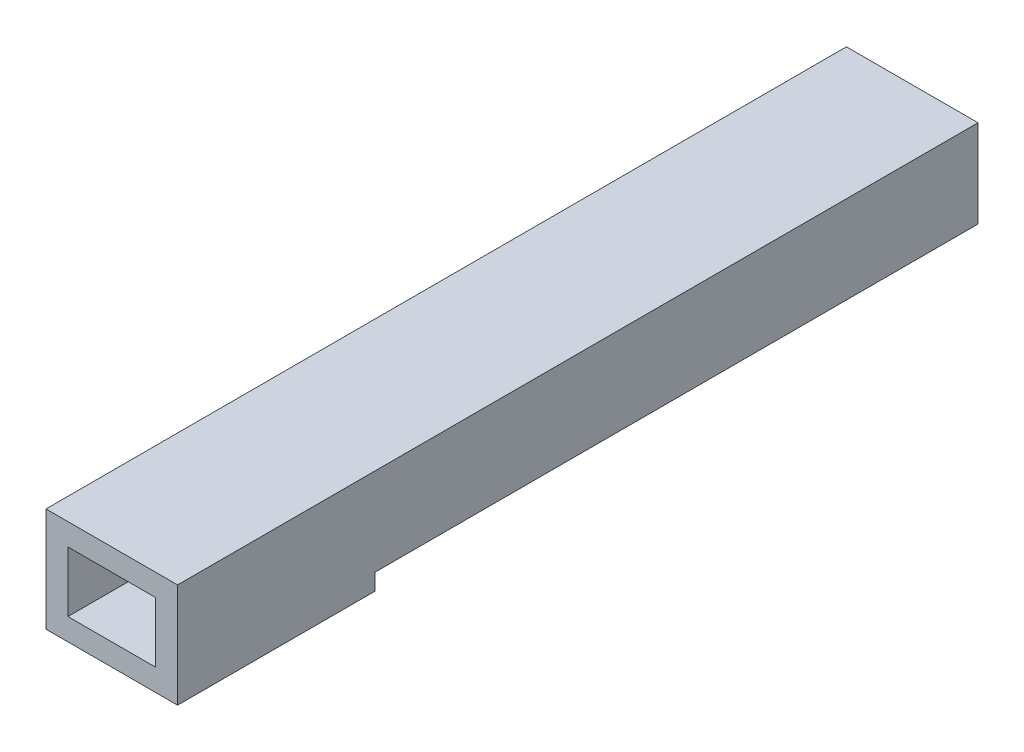
from build123d import *

# Parameters (mm, degrees)
SKETCH1_W                = 120
SKETCH1_H                = 95
SKETCH1_W_2              = 80
SKETCH1_H_2              = 55
BOSS_EXTRUDE1_DEPTH      = 156
BOSS_EXTRUDE1_DEPTH_BACK = 574
CUT_EXTRUDE1_DEPTH       = 550
CUT_EXTRUDE2_DEPTH       = 20


with BuildPart() as part:
    # Sketch1 → Boss-Extrude1 (new body, two sides)
    with BuildSketch(Plane.XY) as boss_extrude1_sk:
        with Locations((0, 212.5)):
            Rectangle(SKETCH1_W, SKETCH1_H)
        with Locations((0, 212.5)):
            Rectangle(SKETCH1_W_2, SKETCH1_H_2, mode=Mode.SUBTRACT)
    extrude(amount=BOSS_EXTRUDE1_DEPTH)
    extrude(boss_extrude1_sk.sketch, amount=-BOSS_EXTRUDE1_DEPTH_BACK)

    # Sketch2 → Cut-Extrude1 (cut)
    with BuildSketch(Plane(origin=(0, 0, -574), x_dir=(-1, 0, 0), z_dir=(0, 0, -1))):
        Polygon((-40, 165), (-30, 180), (-60, 180), (-60, 165), align=None)
        Polygon((30, 180), (60, 180), (60, 165), (40, 165), align=None)
    extrude(amount=-CUT_EXTRUDE1_DEPTH, mode=Mode.SUBTRACT)

    # Sketch3 → Cut-Extrude2 (cut)
    with BuildSketch(Plane.XZ.offset(-165)):
        with BuildLine():
            Line((-15.640352243, -495.413950444), (-15.640352243, -159.146377226))
            ThreePointArc((-15.640352243, -159.146377226), (0, -143.506024984), (15.640352243, -159.146377226))
            Line((15.640352243, -159.146377226), (15.640352243, -495.413950444))
            ThreePointArc((15.640352243, -495.413950444), (0, -511.054302687), (-15.640352243, -495.413950444))
        make_face()
    extrude(amount=-CUT_EXTRUDE2_DEPTH, mode=Mode.SUBTRACT)


solid = part.part
